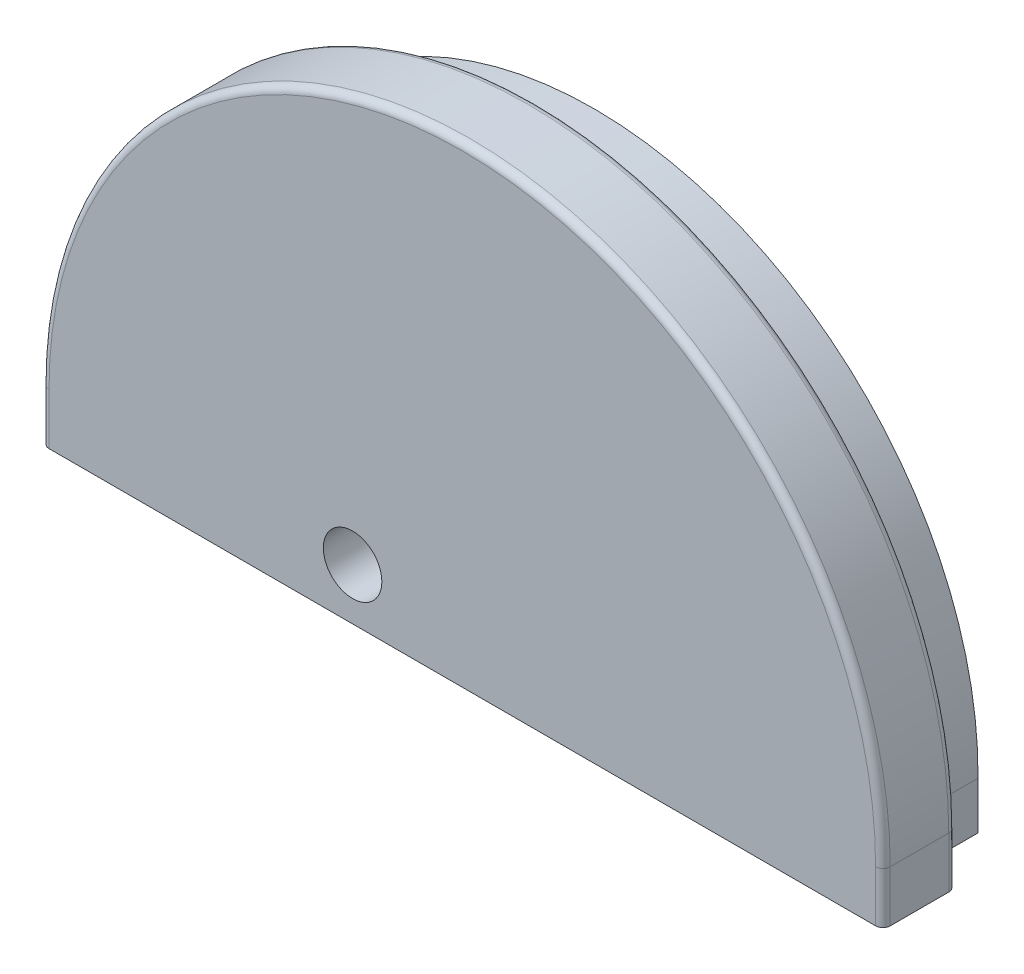
from build123d import *

# Parameters (mm, degrees)
BOSS_EXTRUDE1_DEPTH = 8
BOSS_EXTRUDE2_DEPTH = 10
CUT_EXTRUDE1_REACH  = 20
SKETCH3_R           = 4
FILLET1_R           = 1
CUT_EXTRUDE3_DEPTH  = 4.5
FILLET2_R           = 2


with BuildPart() as part:
    # Sketch1 → Boss-Extrude1 (new body)
    with BuildSketch(Plane.XY):
        with BuildLine():
            Line((49.740147273, 55.788144293), (49.740147273, 48.788144293))
            Line((49.740147273, 48.788144293), (154.737534778, 48.788144293))
            Line((154.737534778, 48.788144293), (154.737534778, 55.264402854))
            ThreePointArc((154.737534778, 55.264402854), (102.50202125, 108.287491165), (49.740147273, 55.788144293))
        make_face()
    extrude(amount=BOSS_EXTRUDE1_DEPTH)

    # Sketch2 → Boss-Extrude2 (add)
    with BuildSketch(Plane.XY.offset(8)):
        with BuildLine():
            Line((159.740147273, 55.788144293), (159.740147273, 48.788144293))
            Line((159.740147273, 48.788144293), (44.740147273, 48.788144293))
            Line((44.740147273, 48.788144293), (44.740147273, 55.788144293))
            ThreePointArc((44.740147273, 55.788144293), (102.240147273, 113.288144293), (159.740147273, 55.788144293))
        make_face()
    extrude(amount=BOSS_EXTRUDE2_DEPTH)

    # Sketch3 → Cut-Extrude1 (cut, up to next)
    with BuildSketch(Plane.XY.offset(18), mode=Mode.PRIVATE) as cut_extrude1_sk1:
        with Locations((87.240147273, 55.788144293)):
            Circle(SKETCH3_R)
    cut_extrude1_tool1 = extrude(cut_extrude1_sk1.sketch, amount=-CUT_EXTRUDE1_REACH, mode=Mode.PRIVATE) & part.part
    add(cut_extrude1_tool1.solids().sort_by_distance((87.240147, 55.788144, 18))[0], mode=Mode.SUBTRACT)

    # Fillet1
    fillet1_edges = [part.edges().sort_by_distance(p)[0] for p in [
        (159.740147273, 52.288144293, 8),
        (44.740147273, 52.288144293, 8),
        (159.740147273, 52.288144293, 18),
        (44.740147273, 52.288144293, 18),
        (102.240147273, 113.288144293, 8),
        (102.240147273, 113.288144293, 18),
    ]]
    fillet(fillet1_edges, radius=FILLET1_R)

    # Sketch6 → Cut-Extrude3 (cut)
    with BuildSketch(Plane.XY):
        with BuildLine():
            Line((72.39178204, 48.788144293), (57.39178204, 48.788144293))
            Line((57.39178204, 48.788144293), (57.39178204, 58.754668066))
            ThreePointArc((57.39178204, 58.754668066), (64.89178204, 66.254668066), (72.39178204, 58.754668066))
            Line((72.39178204, 58.754668066), (72.39178204, 48.788144293))
        make_face()
    extrude(amount=CUT_EXTRUDE3_DEPTH, mode=Mode.SUBTRACT)

    # Fillet2
    fillet2_edges = [part.edges().sort_by_distance(p)[0] for p in [
        (64.89178204, 66.254668066, 0),
        (57.39178204, 53.771406179, 0),
        (72.39178204, 53.771406179, 0),
        (64.89178204, 66.254668066, 4.5),
        (57.39178204, 53.771406179, 4.5),
        (72.39178204, 53.771406179, 4.5),
    ]]
    fillet(fillet2_edges, radius=FILLET2_R)


solid = part.part
